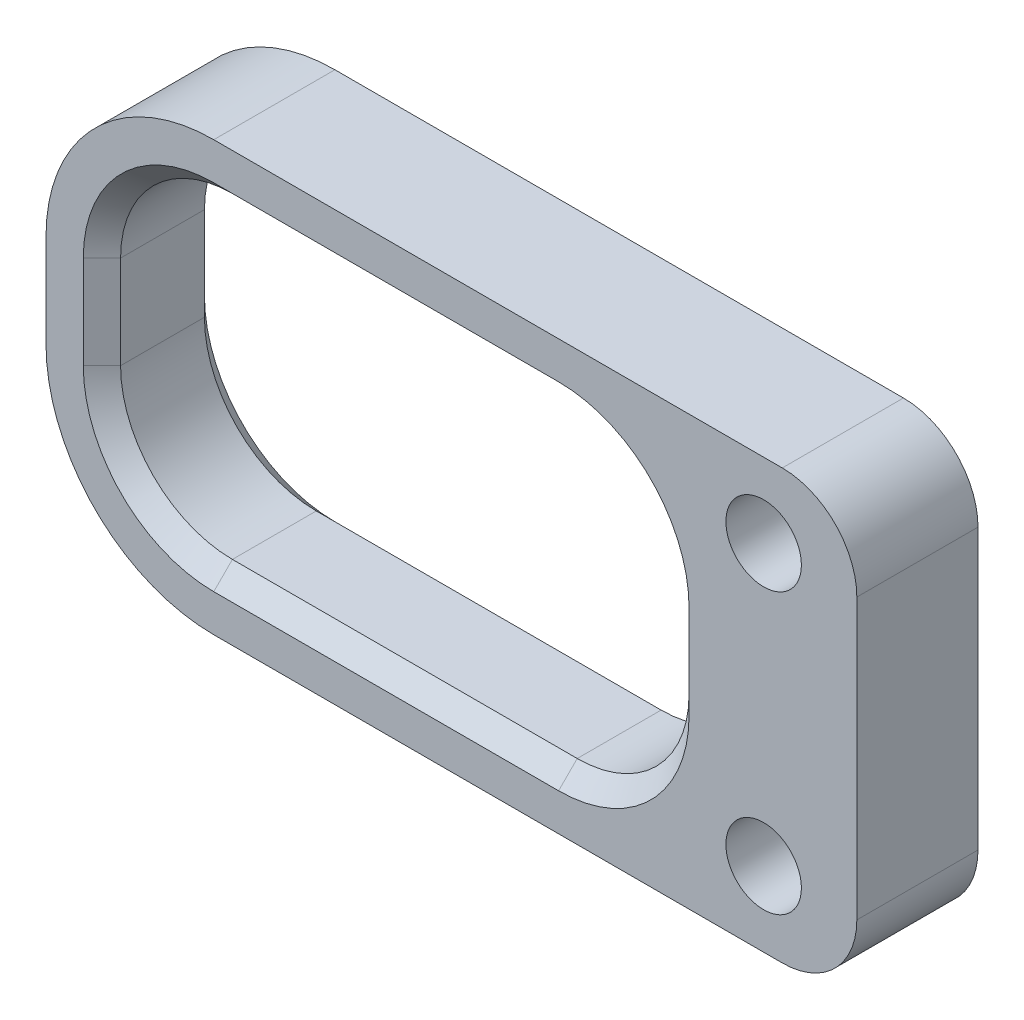
from build123d import *

# Parameters (mm, degrees)
SKETCH1_R           = 2.025483479
BOSS_EXTRUDE1_DEPTH = 6.5
CHAMFER1_SIZE       = 1


with BuildPart() as part:
    # Sketch1 → Boss-Extrude1 (new body)
    with BuildSketch(Plane.XY):
        with BuildLine():
            Line((-29.5, 4), (1, 4))
            ThreePointArc((1, 4), (3.828427125, 2.828427125), (5, 0))
            Line((5, 0), (5, -15))
            ThreePointArc((5, -15), (3.828427125, -17.828427125), (1, -19))
            Line((1, -19), (-29.5, -19))
            ThreePointArc((-29.5, -19), (-35.863961031, -16.363961031), (-38.5, -10))
            Line((-38.5, -10), (-38.5, -5))
            ThreePointArc((-38.5, -5), (-35.863961031, 1.363961031), (-29.5, 4))
        make_face()
        Circle(SKETCH1_R, mode=Mode.SUBTRACT)
        with Locations((0, -15)):
            Circle(SKETCH1_R, mode=Mode.SUBTRACT)
        with BuildLine():
            Line((-29.5, 1), (-11, 1))
            ThreePointArc((-11, 1), (-6.757359313, -0.757359313), (-5, -5))
            Line((-5, -5), (-5, -10))
            ThreePointArc((-5, -10), (-6.757359313, -14.242640687), (-11, -16))
            Line((-11, -16), (-29.5, -16))
            ThreePointArc((-29.5, -16), (-33.742640687, -14.242640687), (-35.5, -10))
            Line((-35.5, -10), (-35.5, -5))
            ThreePointArc((-35.5, -5), (-33.742640687, -0.757359313), (-29.5, 1))
        make_face(mode=Mode.SUBTRACT)
    extrude(amount=BOSS_EXTRUDE1_DEPTH)

    # Chamfer1
    chamfer1_edges = [part.edges().sort_by_distance(p)[0] for p in [
        (-6.757359313, -0.757359313, 0),
        (-20.25, 1, 0),
        (-33.742640687, -0.757359313, 0),
        (-35.5, -7.5, 0),
        (-33.742640687, -14.242640687, 0),
        (-20.25, -16, 0),
        (-6.757359313, -14.242640687, 0),
        (-5, -7.5, 0),
        (-6.757359313, -0.757359313, 6.5),
        (-20.25, 1, 6.5),
        (-33.742640687, -0.757359313, 6.5),
        (-35.5, -7.5, 6.5),
        (-33.742640687, -14.242640687, 6.5),
        (-20.25, -16, 6.5),
        (-6.757359313, -14.242640687, 6.5),
        (-5, -7.5, 6.5),
    ]]
    chamfer(chamfer1_edges, length=CHAMFER1_SIZE)


solid = part.part
